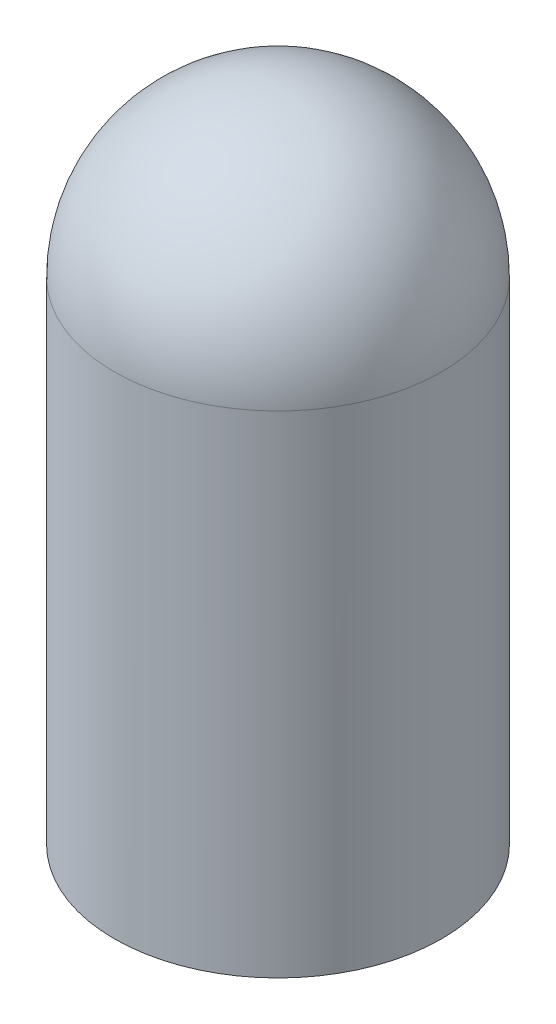
from build123d import *

# Parameters (mm, degrees)
SKETCH1_R      = 2.413
EXTRUDE1_DEPTH = 9.652
FILLET1_R      = 2.413


with BuildPart() as part:
    # Sketch1 → Extrude1 (new body)
    with BuildSketch(Plane(origin=(0, 0, 0), x_dir=(1, 0, 0), z_dir=(0, 1, 0))):
        with Locations(Location((0, 0, 0), (0, 0, 270))):  # turned: the seam where the file's is
            Circle(SKETCH1_R)
    extrude(amount=EXTRUDE1_DEPTH)

    # Fillet1
    fillet1_edges = [part.edges().sort_by_distance(p)[0] for p in [
        (0, 9.652, -2.413),
    ]]
    fillet(fillet1_edges, radius=FILLET1_R)


solid = part.part
